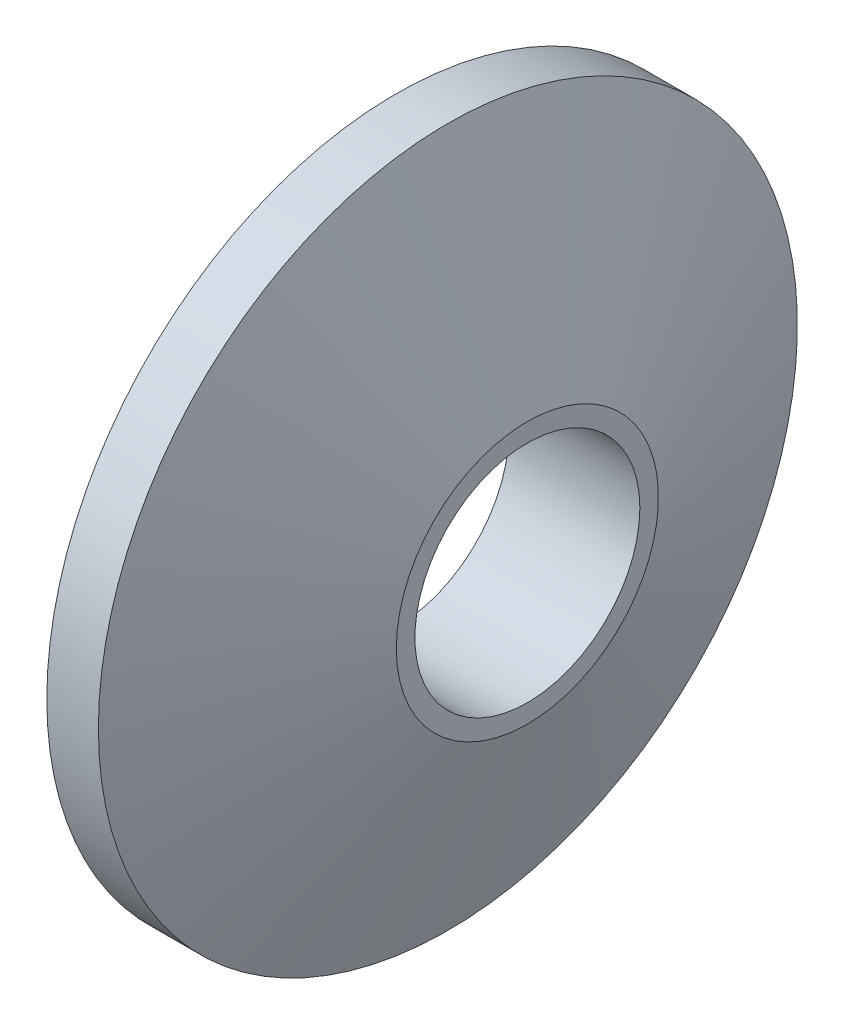
from build123d import *

# Parameters (mm, degrees)
SKETCH5_R          = 2.575
CUT_EXTRUDE3_DEPTH = 4


with BuildPart() as part:
    # Sketch1 → Revolve1 (revolve)
    with BuildSketch(Plane.XY):
        Polygon((0, 0), (0, 8), (1.180148829, 8), (3, 3), (3, 0), align=None)
    revolve(axis=Axis((-13.276595745, 0, 0), (1, 0, 0)))

    # Sketch5 → Cut-Extrude3 (cut, through all)
    with BuildSketch(Plane(origin=(3, 0, 0), x_dir=(0, 0, -1), z_dir=(1, 0, 0))):
        Circle(SKETCH5_R)
    extrude(amount=-CUT_EXTRUDE3_DEPTH, mode=Mode.SUBTRACT)


solid = part.part
